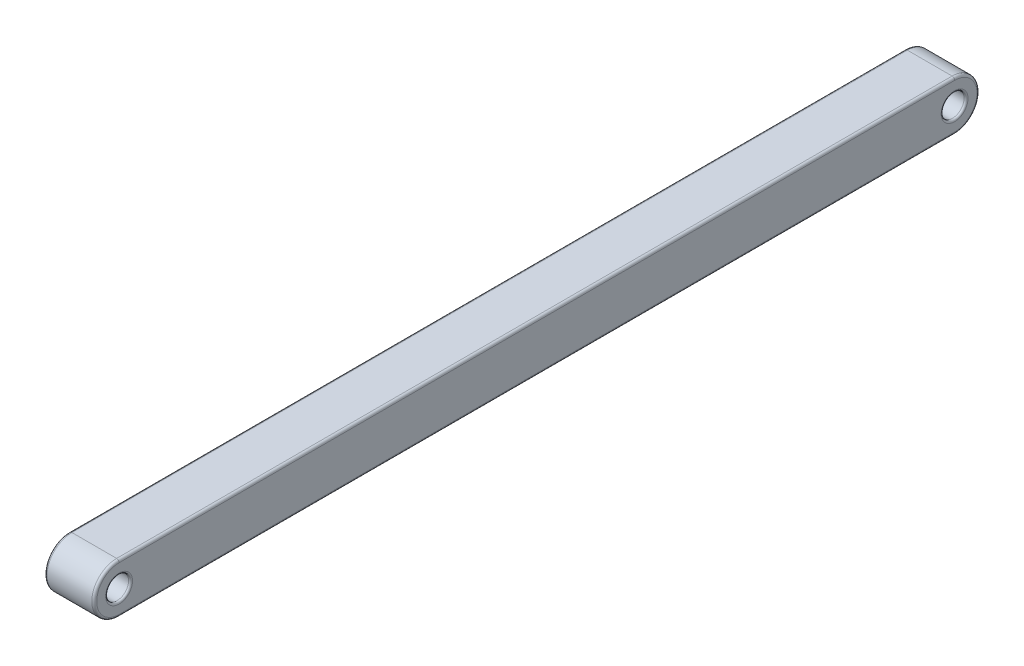
from build123d import *

# Parameters (mm, degrees)
SKETCH1_R           = 0.575
BOSS_EXTRUDE1_DEPTH = 2.5
FILLET1_R           = 0.125
FILLET2_R           = 0.1


with BuildPart() as part:
    # Sketch1 → Boss-Extrude1 (new body)
    with BuildSketch(Plane(origin=(0, 0, 0), x_dir=(0, 0, -1), z_dir=(1, 0, 0))):
        with BuildLine():
            ThreePointArc((41, 0), (42.25, -1.25), (41, -2.5))
            Line((41, -2.5), (40, -2.5))
            Line((40, -2.5), (0, -2.5))
            Line((0, -2.5), (-1, -2.5))
            ThreePointArc((-1, -2.5), (-2.25, -1.25), (-1, 0))
            Line((-1, 0), (0, 0))
            Line((0, 0), (40, 0))
            Line((40, 0), (41, 0))
        make_face()
        with Locations((41, -1.25)):
            Circle(SKETCH1_R, mode=Mode.SUBTRACT)
        with Locations((-1, -1.25)):
            Circle(SKETCH1_R, mode=Mode.SUBTRACT)
    extrude(amount=BOSS_EXTRUDE1_DEPTH)

    # Fillet1
    fillet1_edges = [part.edges().sort_by_distance(p)[0] for p in [
        (0, -1.25, 2.25),
        (0, 0, -20),
        (0, -1.25, -42.25),
        (2.5, 0, -20),
        (2.5, -1.25, 2.25),
        (2.5, -2.5, -20),
        (2.5, -1.25, -42.25),
        (0, -2.5, -20),
    ]]
    fillet(fillet1_edges, radius=FILLET1_R)

    # Fillet2
    fillet2_edges = [part.edges().sort_by_distance(p)[0] for p in [
        (2.5, -1.25, -40.425),
        (2.5, -1.25, 1.575),
        (0, -1.25, 1.575),
        (0, -1.25, -40.425),
    ]]
    fillet(fillet2_edges, radius=FILLET2_R)


solid = part.part
